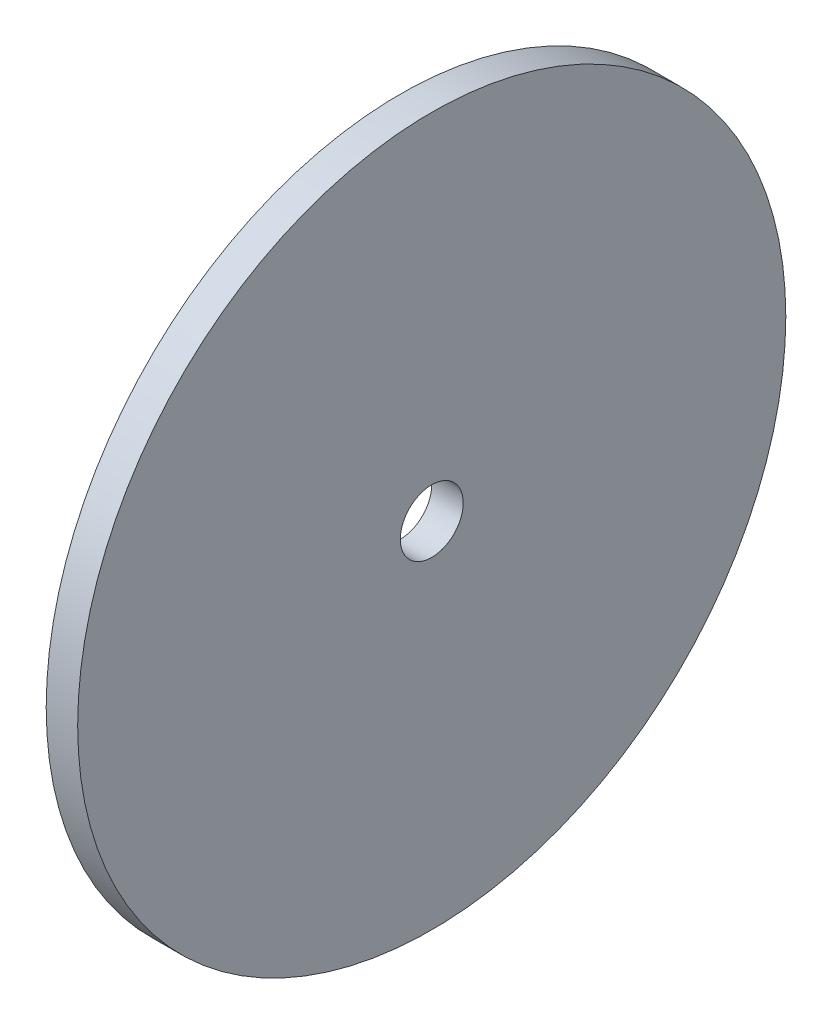
from build123d import *

# Parameters (mm, degrees)
SKETCH1_R           = 45
SKETCH1_R_2         = 4
BOSS_EXTRUDE1_DEPTH = 2


with BuildPart() as part:
    # Sketch1 → Boss-Extrude1 (new body, symmetric)
    with BuildSketch(Plane(origin=(0, 0, 0), x_dir=(0, 0, -1), z_dir=(1, 0, 0))):
        Circle(SKETCH1_R)
        Circle(SKETCH1_R_2, mode=Mode.SUBTRACT)
    extrude(amount=BOSS_EXTRUDE1_DEPTH, both=True)


solid = part.part
